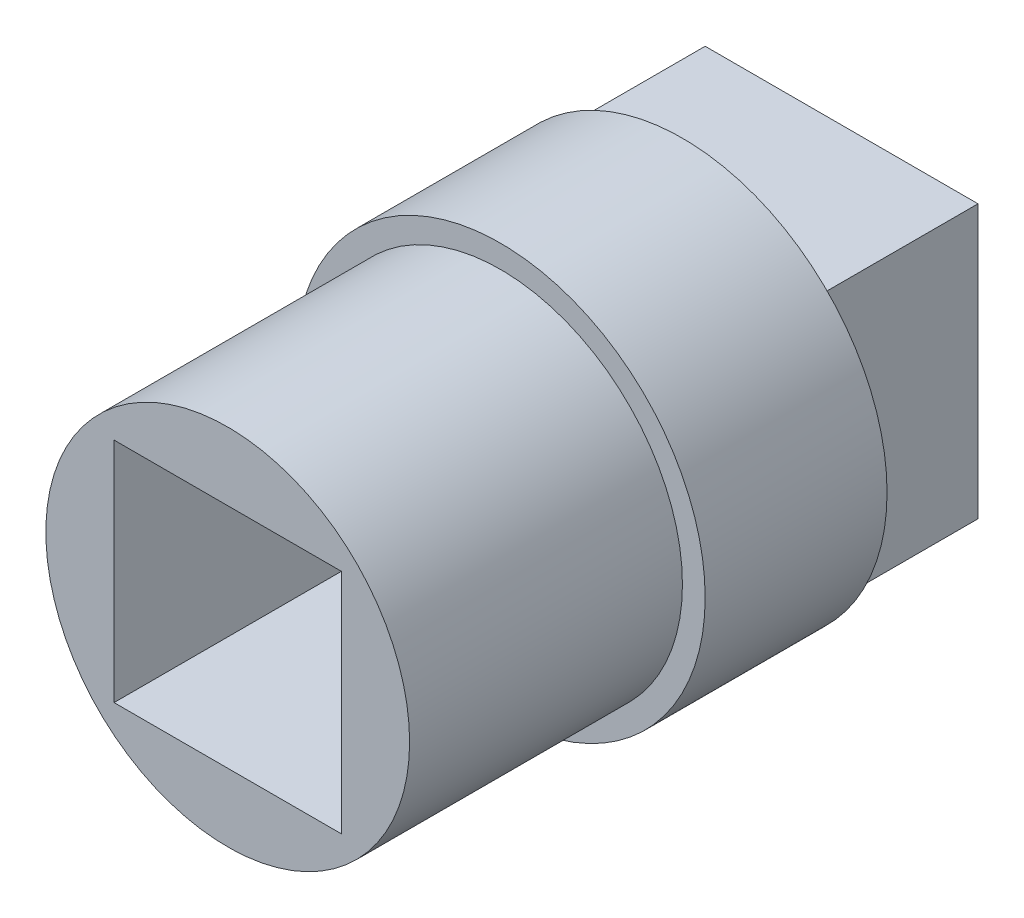
from build123d import *

# Parameters (mm, degrees)
CROQUIS1_W              = 6
CROQUIS1_H              = 6
SALIENTE_EXTRUIR1_DEPTH = 3.5
CROQUIS2_R              = 4.5
SALIENTE_EXTRUIR2_DEPTH = 4
CROQUIS3_R              = 4
SALIENTE_EXTRUIR3_DEPTH = 6
CROQUIS4_W              = 5
CROQUIS4_H              = 5
CORTAR_EXTRUIR1_DEPTH   = 5


with BuildPart() as part:
    # Croquis1 → Saliente-Extruir1 (new body)
    with BuildSketch(Plane.XY):
        Rectangle(CROQUIS1_W, CROQUIS1_H)
    extrude(amount=SALIENTE_EXTRUIR1_DEPTH)

    # Croquis2 → Saliente-Extruir2 (add)
    with BuildSketch(Plane.XY.offset(3.5)):
        Circle(CROQUIS2_R)
    extrude(amount=SALIENTE_EXTRUIR2_DEPTH)

    # Croquis3 → Saliente-Extruir3 (add)
    with BuildSketch(Plane.XY.offset(7.5)):
        Circle(CROQUIS3_R)
    extrude(amount=SALIENTE_EXTRUIR3_DEPTH)

    # Croquis4 → Cortar-Extruir1 (cut)
    with BuildSketch(Plane.XY.offset(13.5)):
        Rectangle(CROQUIS4_W, CROQUIS4_H)
    extrude(amount=-CORTAR_EXTRUIR1_DEPTH, mode=Mode.SUBTRACT)


solid = part.part
